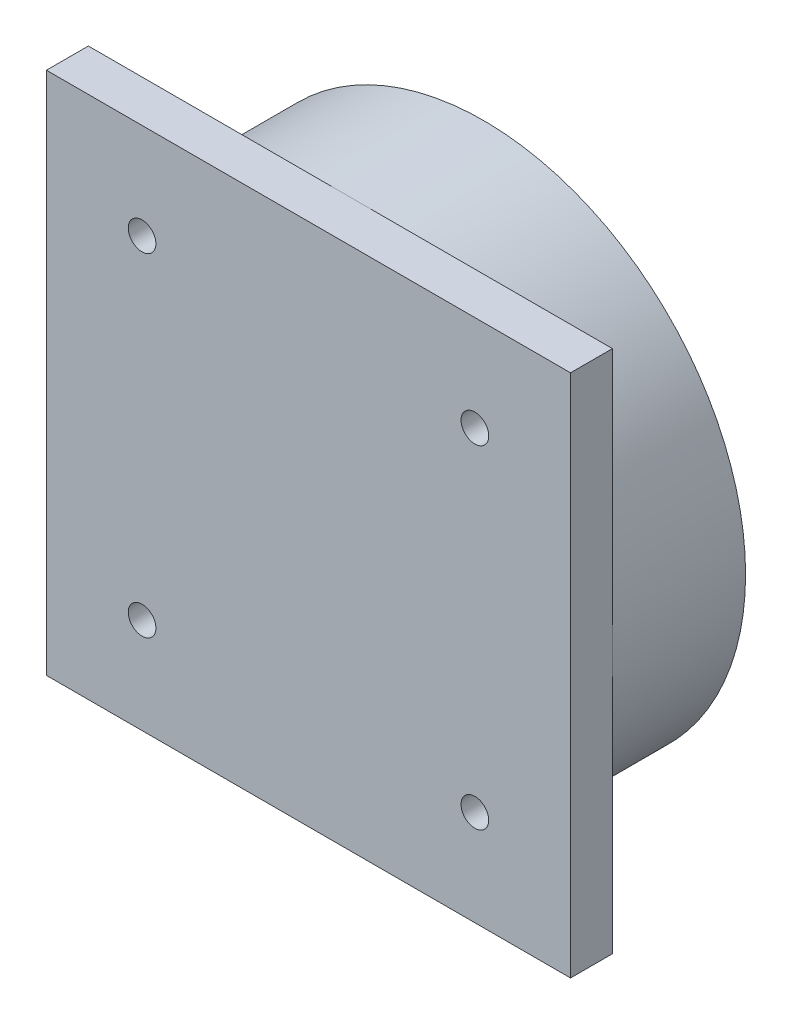
from build123d import *

# Parameters (mm, degrees)
SKETCH1_R           = 25
BOSS_EXTRUDE1_DEPTH = 12.7
SKETCH2_W           = 50
SKETCH2_H           = 50
BOSS_EXTRUDE2_DEPTH = 4
SKETCH3_R           = 1.32
CUT_EXTRUDE1_DEPTH  = 17.7


with BuildPart() as part:
    # Sketch1 → Boss-Extrude1 (new body)
    with BuildSketch(Plane.XY):
        Circle(SKETCH1_R)
    extrude(amount=BOSS_EXTRUDE1_DEPTH)

    # Sketch2 → Boss-Extrude2 (add)
    with BuildSketch(Plane.XY.offset(12.7)):
        Rectangle(SKETCH2_W, SKETCH2_H)
    extrude(amount=BOSS_EXTRUDE2_DEPTH)

    # Sketch3 → Cut-Extrude1 (cut, through all)
    with BuildSketch(Plane.XY.offset(16.7)):
        with Locations((-15.875, 15.875)):
            Circle(SKETCH3_R)
        with Locations((15.875, 15.875)):
            Circle(SKETCH3_R)
        with Locations((15.875, -15.875)):
            Circle(SKETCH3_R)
        with Locations((-15.875, -15.875)):
            Circle(SKETCH3_R)
    extrude(amount=-CUT_EXTRUDE1_DEPTH, mode=Mode.SUBTRACT)


solid = part.part
